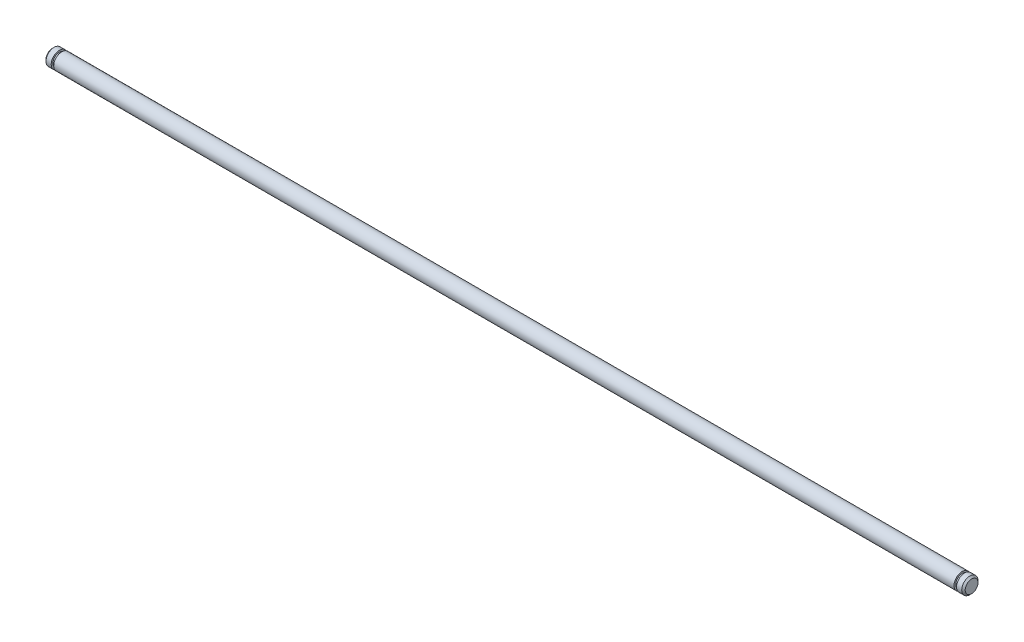
from build123d import *

# Parameters (mm, degrees)
CHAMFER1_SIZE = 0.508


with BuildPart() as part:
    # Sketch1 → Revolve1 (revolve)
    with BuildSketch(Plane.XY):
        Polygon((-152.7556, 0), (116.3066, 0), (116.3066, 2.38125), (114.2746, 2.38125), (114.2746, 1.8669), (113.538, 1.8669), (113.538, 2.38125), (-149.987, 2.38125), (-149.987, 1.8669), (-150.7236, 1.8669), (-150.7236, 2.38125), (-152.7556, 2.38125), align=None)
    revolve(axis=Axis((116.3066, 0, 0), (1, 0, 0)))

    # Chamfer1
    chamfer1_edges = [part.edges().sort_by_distance(p)[0] for p in [
        (-152.7556, -2.38125, 0),
        (116.3066, -2.38125, 0),
    ]]
    chamfer(chamfer1_edges, length=CHAMFER1_SIZE)


solid = part.part
